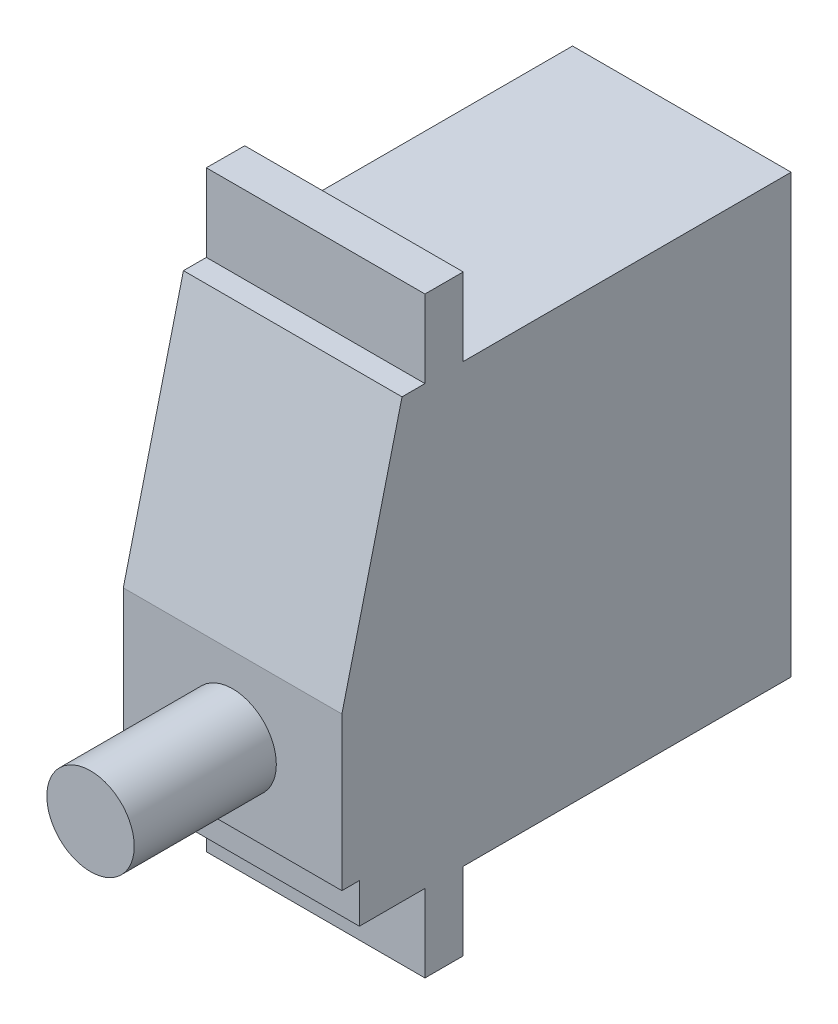
from build123d import *

# Parameters (mm, degrees)
BOSS_EXTRUDE1_DEPTH = 19.999999553
SKETCH2_W           = 29.999999329
SKETCH2_H           = 7.099999115
CUT_EXTRUDE1_DEPTH  = 55.335457568
SKETCH3_W           = 7.599998266
SKETCH3_H           = 7.099999115
CUT_EXTRUDE2_DEPTH  = 55.335457568
SKETCH4_W           = 1.599997282
SKETCH4_H           = 3.620889969
CUT_EXTRUDE3_DEPTH  = 55.335457568
BOSS_EXTRUDE2_REACH = 56.335
SKETCH6_W           = 3.500001505
SKETCH6_H           = 7.10000284
SKETCH7_R           = 4
BOSS_EXTRUDE3_DEPTH = 7
MOVE_FACE2_BY       = 6


with BuildPart() as part:
    # Sketch1 → Boss-Extrude1 (new body)
    with BuildSketch(Plane(origin=(10, 0, 0), x_dir=(0, 0, -1), z_dir=(1, 0, 0))):
        Polygon((0, 29.379108921), (-35.59999913, 29.379108921), (-41.0999991, 7.000000216), (-41.0999991, -17.7208893), (0, -17.7208893), align=None)
    extrude(amount=-BOSS_EXTRUDE1_DEPTH)

    # Sketch2 → Cut-Extrude1 (cut, through all)
    with BuildSketch(Plane(origin=(10, 0, 0), x_dir=(0, 0, -1), z_dir=(1, 0, 0))):
        with Locations((-14.999999665, -14.170889742)):
            Rectangle(SKETCH2_W, SKETCH2_H)
    extrude(amount=-CUT_EXTRUDE1_DEPTH, mode=Mode.SUBTRACT)

    # Sketch3 → Cut-Extrude2 (cut, through all)
    with BuildSketch(Plane(origin=(10, 0, 0), x_dir=(0, 0, -1), z_dir=(1, 0, 0))):
        with Locations((-37.299999967, -14.170889742)):
            Rectangle(SKETCH3_W, SKETCH3_H)
    extrude(amount=-CUT_EXTRUDE2_DEPTH, mode=Mode.SUBTRACT)

    # Sketch4 → Cut-Extrude3 (cut, through all)
    with BuildSketch(Plane(origin=(10, 0, 0), x_dir=(0, 0, -1), z_dir=(1, 0, 0))):
        with Locations((-40.300000459, -8.810445201)):
            Rectangle(SKETCH4_W, SKETCH4_H)
    extrude(amount=-CUT_EXTRUDE3_DEPTH, mode=Mode.SUBTRACT)

    # Boss-Extrude2: up to this plane
    boss_extrude2_end = Plane(origin=(-9.873244788, 0, -0.038787862), z_dir=(-0.9999922832070416, 0, -0.003928552706520363))
    # Sketch6 → Boss-Extrude2 (add, up to the surface)
    with BuildSketch(Plane(origin=(10, 0, 0), x_dir=(0, 0, -1), z_dir=(1, 0, 0)), mode=Mode.PRIVATE) as boss_extrude2_sk1:
        with Locations((-31.750000082, 32.929110341)):
            Rectangle(SKETCH6_W, SKETCH6_H)
    boss_extrude2_tool1 = split(extrude(boss_extrude2_sk1.sketch, amount=-BOSS_EXTRUDE2_REACH, mode=Mode.PRIVATE), bisect_by=boss_extrude2_end, keep=Keep.BOTH, mode=Mode.PRIVATE)
    add(boss_extrude2_tool1.solids().sort_by_distance((10, 32.92911, 31.75))[0])

    # Sketch7 → Boss-Extrude3 (add)
    with BuildSketch(Plane.XY.offset(41.0999991)):
        Circle(SKETCH7_R)
    extrude(amount=BOSS_EXTRUDE3_DEPTH)

    # Move Face2: a face moved outward by 6.0
    extrude(part.faces().sort_by_distance((0, 0, 48.0999991))[0], amount=MOVE_FACE2_BY, dir=(0, 0, 1))


solid = part.part
